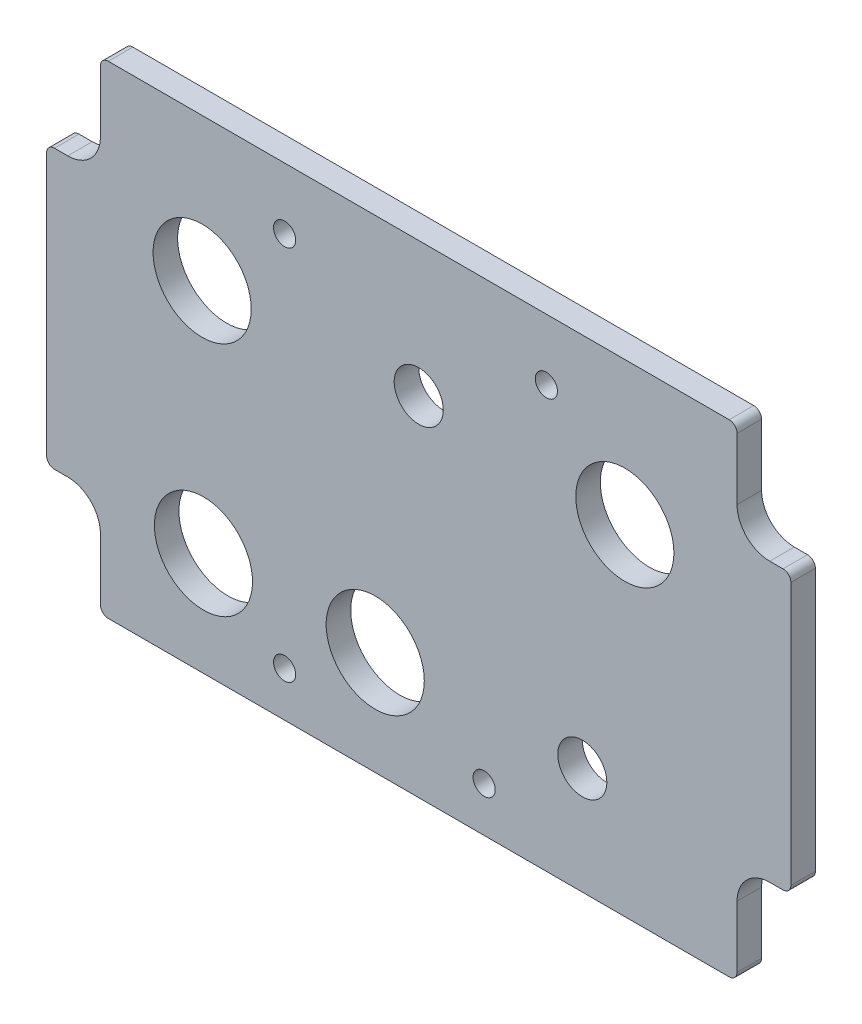
from build123d import *

# Parameters (mm, degrees)
BOSS_EXTRUDE1_DEPTH   = 4.7625
F_6_CLEARANCE_HOLE1_D = 4.3053
SKETCH4_R             = 4.7625
SKETCH4_R_2           = 9.525
CUT_EXTRUDE1_DEPTH    = 5.7625


with BuildPart() as part:
    # Sketch1 → Boss-Extrude1 (new body)
    with BuildSketch(Plane.XY):
        with BuildLine():
            Line((133.2865, 94.45625), (12.7635, 94.45625))
            ThreePointArc((12.7635, 94.45625), (11.685869265, 94.009880735), (11.2395, 92.93225))
            Line((11.2395, 92.93225), (11.2395, 80.9625))
            ThreePointArc((11.2395, 80.9625), (9.379628061, 76.472371939), (4.8895, 74.6125))
            Line((4.8895, 74.6125), (2.31775, 74.6125))
            ThreePointArc((2.31775, 74.6125), (1.240119265, 74.166130735), (0.79375, 73.0885))
            Line((0.79375, 73.0885), (0.79375, 22.1615))
            ThreePointArc((0.79375, 22.1615), (1.240119265, 21.083869265), (2.31775, 20.6375))
            Line((2.31775, 20.6375), (4.8895, 20.6375))
            ThreePointArc((4.8895, 20.6375), (9.379628061, 18.777628061), (11.2395, 14.2875))
            Line((11.2395, 14.2875), (11.2395, 2.31775))
            ThreePointArc((11.2395, 2.31775), (11.685869265, 1.240119265), (12.7635, 0.79375))
            Line((12.7635, 0.79375), (133.2865, 0.79375))
            ThreePointArc((133.2865, 0.79375), (134.364130735, 1.240119265), (134.8105, 2.31775))
            Line((134.8105, 2.31775), (134.8105, 14.2875))
            ThreePointArc((134.8105, 14.2875), (136.670371939, 18.777628061), (141.1605, 20.6375))
            Line((141.1605, 20.6375), (143.73225, 20.6375))
            ThreePointArc((143.73225, 20.6375), (144.809880735, 21.083869265), (145.25625, 22.1615))
            Line((145.25625, 22.1615), (145.25625, 73.0885))
            ThreePointArc((145.25625, 73.0885), (144.809880735, 74.166130735), (143.73225, 74.6125))
            Line((143.73225, 74.6125), (141.1605, 74.6125))
            ThreePointArc((141.1605, 74.6125), (136.670371939, 76.472371939), (134.8105, 80.9625))
            Line((134.8105, 80.9625), (134.8105, 92.93225))
            ThreePointArc((134.8105, 92.93225), (134.364130735, 94.009880735), (133.2865, 94.45625))
        make_face()
    extrude(amount=BOSS_EXTRUDE1_DEPTH)

    # #6 Clearance Hole1 (through all)
    with Locations(Plane.XY.offset(4.7625)):
        with Locations((46.99, 82.55), (97.79, 82.55), (85.725, 9.525), (46.99, 9.525)):
            Hole(F_6_CLEARANCE_HOLE1_D / 2)

    # Sketch4 → Cut-Extrude1 (cut, through all)
    with BuildSketch(Plane.XY.offset(4.7625)):
        with Locations((73.025, 68.326)):
            Circle(SKETCH4_R)
        with Locations((104.775, 21.59)):
            Circle(SKETCH4_R)
        with Locations((30.988, 66.675)):
            Circle(SKETCH4_R_2)
        with Locations((113.03, 66.675)):
            Circle(SKETCH4_R_2)
        with Locations((31.242, 20.955)):
            Circle(SKETCH4_R_2)
        with Locations((64.5795, 20.955)):
            Circle(SKETCH4_R_2)
    extrude(amount=-CUT_EXTRUDE1_DEPTH, mode=Mode.SUBTRACT)


solid = part.part
